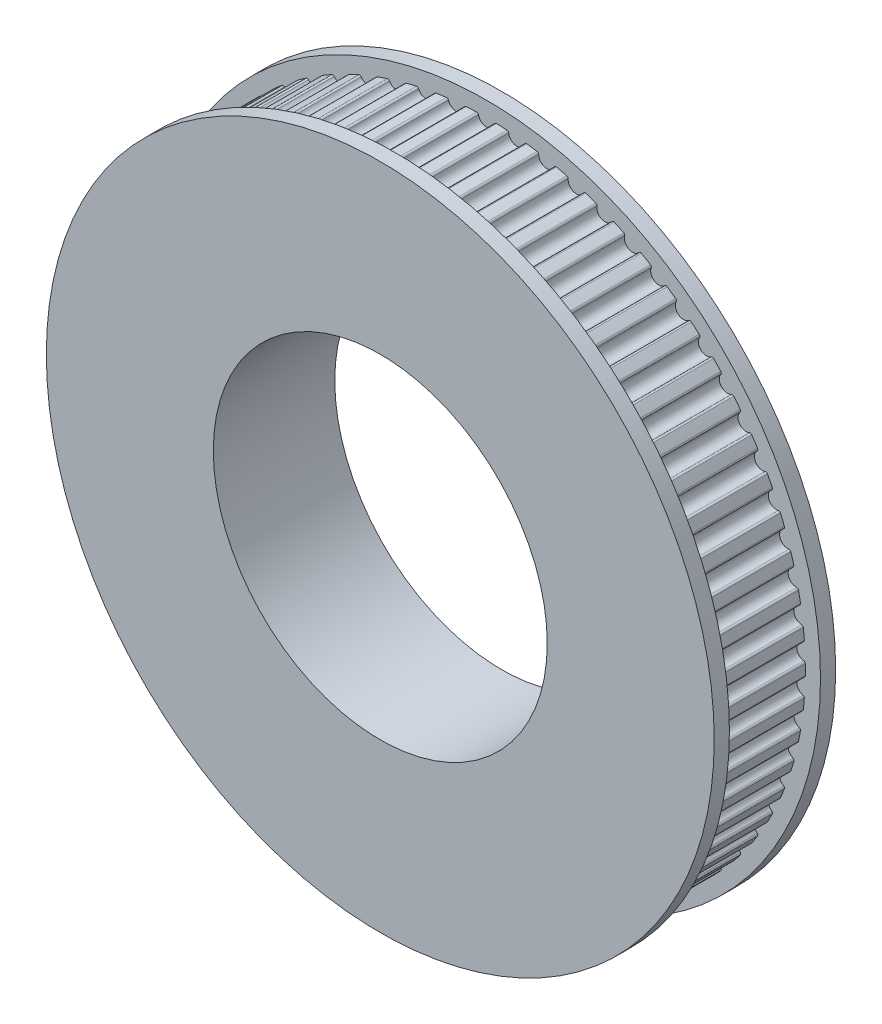
from build123d import *

# Parameters (mm, degrees)
SKETCH1_R           = 11
BOSS_EXTRUDE1_DEPTH = 6
SKETCH3_R           = 22
SKETCH3_R_2         = 11
BOSS_EXTRUDE2_DEPTH = 1
SKETCH4_R           = 22
SKETCH4_R_2         = 11
BOSS_EXTRUDE3_DEPTH = 1


with BuildPart() as part:
    # Sketch1 → Boss-Extrude1 (new body)
    with BuildSketch(Plane.XY):
        with BuildLine():
            ThreePointArc((-0.528729208, 20.890248339), (-0.573745596, 20.963017024), (-0.655019151, 20.989782039))
            ThreePointArc((-0.655019151, 20.989782039), (-0.999220235, 20.976214126), (-1.343152463, 20.95700221))
            ThreePointArc((-1.343152463, 20.95700221), (-1.421513828, 20.922632846), (-1.459409275, 20.845914583))
            ThreePointArc((-1.459409275, 20.845914583), (-1.944846649, 20.367355539), (-2.512079432, 20.74539677))
            ThreePointArc((-2.512079432, 20.74539677), (-2.563809085, 20.813556874), (-2.647258804, 20.832475153))
            ThreePointArc((-2.647258804, 20.832475153), (-2.988611607, 20.786250283), (-3.329160274, 20.734432523))
            ThreePointArc((-3.329160274, 20.734432523), (-3.403899797, 20.692770065), (-3.434331116, 20.612796997))
            ThreePointArc((-3.434331116, 20.612796997), (-3.872080463, 20.090261149), (-4.472679875, 20.412671677))
            ThreePointArc((-4.472679875, 20.412671677), (-4.530654323, 20.47560593), (-4.615524471, 20.486506145))
            ThreePointArc((-4.615524471, 20.486506145), (-4.950937649, 20.408042938), (-5.285018694, 20.324088604))
            ThreePointArc((-5.285018694, 20.324088604), (-5.355459522, 20.275510353), (-5.378151123, 20.193006729))
            ThreePointArc((-5.378151123, 20.193006729), (-5.764248116, 19.631226244), (-6.392775037, 19.895086267))
            ThreePointArc((-6.392775037, 19.895086267), (-6.456469253, 19.952224728), (-6.541991234, 19.955008165))
            ThreePointArc((-6.541991234, 19.955008165), (-6.868427233, 19.845017196), (-7.193015166, 19.729686592))
            ThreePointArc((-7.193015166, 19.729686592), (-7.258519377, 19.674632481), (-7.27326576, 19.590345465))
            ThreePointArc((-7.27326576, 19.590345465), (-7.604213846, 18.994407913), (-8.254976238, 19.197327876))
            ThreePointArc((-8.254976238, 19.197327876), (-8.323813397, 19.248153089), (-8.409212711, 19.242794542))
            ThreePointArc((-8.409212711, 19.242794542), (-8.723715276, 19.102271906), (-9.035870579, 18.956609482))
            ThreePointArc((-9.035870579, 18.956609482), (-9.095844956, 18.89557809), (-9.102512576, 18.810270999))
            ThreePointArc((-9.102512576, 18.810270999), (-9.375314638, 18.185573283), (-10.042419096, 18.32571551))
            ThreePointArc((-10.042419096, 18.32571551), (-10.115775799, 18.369767195), (-10.200279056, 18.356315191))
            ThreePointArc((-10.200279056, 18.356315191), (-10.500000003, 18.186533483), (-10.796895749, 18.011858382))
            ThreePointArc((-10.796895749, 18.011858382), (-10.850797155, 17.945402417), (-10.849325628, 17.859847807))
            ThreePointArc((-10.849325628, 17.859847807), (-11.061511128, 17.212047285), (-11.738916251, 17.288142628))
            ThreePointArc((-11.738916251, 17.288142628), (-11.816128169, 17.325021845), (-11.898970094, 17.303598207))
            ThreePointArc((-11.898970094, 17.303598207), (-12.181195104, 17.106094997), (-12.460142559, 16.903989103))
            ThreePointArc((-12.460142559, 16.903989103), (-12.507482854, 16.832710402), (-12.497885508, 16.747683066))
            ThreePointArc((-12.497885508, 16.747683066), (-12.647532861, 16.082646322), (-13.329103964, 16.094005648))
            ThreePointArc((-13.329103964, 16.094005648), (-13.409471852, 16.123378414), (-13.489902216, 16.094177158))
            ThreePointArc((-13.489902216, 16.094177158), (-13.752075416, 15.870741065), (-14.010548389, 15.643034681))
            ThreePointArc((-14.010548389, 15.643034681), (-14.050898852, 15.567578754), (-14.033262601, 15.483848715))
            ThreePointArc((-14.033262601, 15.483848715), (-14.119016578, 14.807598423), (-14.798581246, 14.754118861))
            ThreePointArc((-14.798581246, 14.754118861), (-14.881377281, 14.775719171), (-14.958667695, 14.739004749))
            ThreePointArc((-14.958667695, 14.739004749), (-15.198414803, 14.491659245), (-15.434072523, 14.240414515))
            ThreePointArc((-15.434072523, 14.240414515), (-15.467067734, 14.161464703), (-15.441552295, 14.079790232))
            ThreePointArc((-15.441552295, 14.079790232), (-15.462636294, 13.39845062), (-16.134040286, 13.280616489))
            ThreePointArc((-16.134040286, 13.280616489), (-16.218514654, 13.294248728), (-16.291965163, 13.250353631))
            ThreePointArc((-16.291965163, 13.250353631), (-16.507114993, 12.981338714), (-16.717823306, 12.70883095))
            ThreePointArc((-16.717823306, 12.70883095), (-16.743164455, 12.627102234), (-16.710000901, 12.548222988))
            ThreePointArc((-16.710000901, 12.548222988), (-16.666223982, 11.867964373), (-17.323386958, 11.686842798))
            ThreePointArc((-17.323386958, 11.686842798), (-17.408774646, 11.692383509), (-17.477720071, 11.641705258))
            ThreePointArc((-17.477720071, 11.641705258), (-17.666324193, 11.35345717), (-17.850174892, 11.062154244))
            ThreePointArc((-17.850174892, 11.062154244), (-17.867632487, 10.978386773), (-17.82712115, 10.903017094))
            ThreePointArc((-17.82712115, 10.903017094), (-17.718879765, 10.230000003), (-18.355850355, 9.987231248))
            ThreePointArc((-18.355850355, 9.987231248), (-18.44137808, 9.984630255), (-18.50519404, 9.927627799))
            ThreePointArc((-18.50519404, 9.927627799), (-18.665544425, 9.62275696), (-18.820872531, 9.315296955))
            ThreePointArc((-18.820872531, 9.315296955), (-18.830288471, 9.23024934), (-18.78279623, 9.159071789))
            ThreePointArc((-18.78279623, 9.159071789), (-18.611070628, 8.499391169), (-19.222080329, 8.197173786))
            ThreePointArc((-19.222080329, 8.197173786), (-19.306973537, 8.186454643), (-19.365082106, 8.123644206))
            ThreePointArc((-19.365082106, 8.123644206), (-19.495726597, 7.804911572), (-19.621125433, 7.484078896))
            ThreePointArc((-19.621125433, 7.484078896), (-19.622414448, 7.39852134), (-19.568371399, 7.332180511))
            ThreePointArc((-19.568371399, 7.332180511), (-19.334716754, 6.691810533), (-19.914232167, 6.332881448))
            ThreePointArc((-19.914232167, 6.332881448), (-19.997722053, 6.31414123), (-20.04959699, 6.246091633))
            ThreePointArc((-20.04959699, 6.246091633), (-20.149352449, 5.916383697), (-20.243686385, 5.585083858))
            ThreePointArc((-20.243686385, 5.585083858), (-20.236836801, 5.499791186), (-20.176732366, 5.438887871))
            ThreePointArc((-20.176732366, 5.438887871), (-19.883264691, 4.823627824), (-20.426037635, 4.411237556))
            ThreePointArc((-20.426037635, 4.411237556), (-20.507368101, 4.384645977), (-20.552539619, 4.311973487))
            ThreePointArc((-20.552539619, 4.311973487), (-20.620502646, 3.974276135), (-20.682917379, 3.635509437))
            ThreePointArc((-20.682917379, 3.635509437), (-20.667991226, 3.551254071), (-20.60236972, 3.496339821))
            ThreePointArc((-20.60236972, 3.496339821), (-20.251746704, 2.911761595), (-20.752861743, 2.449644813))
            ThreePointArc((-20.752861743, 2.449644813), (-20.831296248, 2.41544269), (-20.869355267, 2.338805442))
            ThreePointArc((-20.869355267, 2.338805442), (-20.904910377, 1.996176913), (-20.934840669, 1.653011279))
            ThreePointArc((-20.934840669, 1.653011279), (-20.911973121, 1.570556249), (-20.841428824, 1.522128375))
            ThreePointArc((-20.841428824, 1.522128375), (-20.436825763, 0.973526001), (-20.891744721, 0.465867707))
            ThreePointArc((-20.891744721, 0.465867707), (-20.96657295, 0.424364781), (-20.997174801, 0.344456812))
            ThreePointArc((-20.997174801, 0.344456812), (-21.000000003, 3e-09), (-20.997174801, -0.344456805))
            ThreePointArc((-20.997174801, -0.344456805), (-20.96657295, -0.424364774), (-20.891744721, -0.4658677))
            ThreePointArc((-20.891744721, -0.4658677), (-20.436825763, -0.973525994), (-20.841428824, -1.522128368))
            ThreePointArc((-20.841428824, -1.522128368), (-20.911973121, -1.570556242), (-20.934840669, -1.653011272))
            ThreePointArc((-20.934840669, -1.653011272), (-20.904910377, -1.996176906), (-20.869355267, -2.338805435))
            ThreePointArc((-20.869355267, -2.338805435), (-20.831296248, -2.415442683), (-20.752861743, -2.449644806))
            ThreePointArc((-20.752861743, -2.449644806), (-20.251746704, -2.911761588), (-20.60236972, -3.496339814))
            ThreePointArc((-20.60236972, -3.496339814), (-20.667991226, -3.551254064), (-20.682917379, -3.63550943))
            ThreePointArc((-20.682917379, -3.63550943), (-20.620502646, -3.974276128), (-20.552539619, -4.31197348))
            ThreePointArc((-20.552539619, -4.31197348), (-20.507368101, -4.38464597), (-20.426037635, -4.411237549))
            ThreePointArc((-20.426037635, -4.411237549), (-19.883264691, -4.823627817), (-20.176732366, -5.438887864))
            ThreePointArc((-20.176732366, -5.438887864), (-20.236836801, -5.499791179), (-20.243686385, -5.585083851))
            ThreePointArc((-20.243686385, -5.585083851), (-20.149352449, -5.91638369), (-20.04959699, -6.246091626))
            ThreePointArc((-20.04959699, -6.246091626), (-19.997722053, -6.314141223), (-19.914232167, -6.332881441))
            ThreePointArc((-19.914232167, -6.332881441), (-19.334716754, -6.691810526), (-19.568371399, -7.332180504))
            ThreePointArc((-19.568371399, -7.332180504), (-19.622414448, -7.398521334), (-19.621125433, -7.484078889))
            ThreePointArc((-19.621125433, -7.484078889), (-19.495726597, -7.804911565), (-19.365082106, -8.123644199))
            ThreePointArc((-19.365082106, -8.123644199), (-19.306973537, -8.186454636), (-19.222080329, -8.197173779))
            ThreePointArc((-19.222080329, -8.197173779), (-18.611070628, -8.499391163), (-18.78279623, -9.159071782))
            ThreePointArc((-18.78279623, -9.159071782), (-18.830288471, -9.230249333), (-18.820872531, -9.315296948))
            ThreePointArc((-18.820872531, -9.315296948), (-18.665544425, -9.622756953), (-18.50519404, -9.927627792))
            ThreePointArc((-18.50519404, -9.927627792), (-18.44137808, -9.984630248), (-18.355850355, -9.987231241))
            ThreePointArc((-18.355850355, -9.987231241), (-17.718879765, -10.229999997), (-17.82712115, -10.903017087))
            ThreePointArc((-17.82712115, -10.903017087), (-17.867632487, -10.978386766), (-17.850174892, -11.062154237))
            ThreePointArc((-17.850174892, -11.062154237), (-17.666324193, -11.353457163), (-17.477720071, -11.641705251))
            ThreePointArc((-17.477720071, -11.641705251), (-17.408774646, -11.692383502), (-17.323386958, -11.686842791))
            ThreePointArc((-17.323386958, -11.686842791), (-16.666223982, -11.867964366), (-16.710000901, -12.548222981))
            ThreePointArc((-16.710000901, -12.548222981), (-16.743164455, -12.627102227), (-16.717823306, -12.708830943))
            ThreePointArc((-16.717823306, -12.708830943), (-16.507114993, -12.981338707), (-16.291965163, -13.250353624))
            ThreePointArc((-16.291965163, -13.250353624), (-16.218514654, -13.294248721), (-16.134040286, -13.280616482))
            ThreePointArc((-16.134040286, -13.280616482), (-15.462636294, -13.398450613), (-15.441552295, -14.079790225))
            ThreePointArc((-15.441552295, -14.079790225), (-15.467067734, -14.161464696), (-15.434072523, -14.240414508))
            ThreePointArc((-15.434072523, -14.240414508), (-15.198414803, -14.491659238), (-14.958667695, -14.739004742))
            ThreePointArc((-14.958667695, -14.739004742), (-14.881377281, -14.775719164), (-14.798581246, -14.754118854))
            ThreePointArc((-14.798581246, -14.754118854), (-14.119016578, -14.807598416), (-14.033262601, -15.483848708))
            ThreePointArc((-14.033262601, -15.483848708), (-14.050898852, -15.567578747), (-14.010548389, -15.643034674))
            ThreePointArc((-14.010548389, -15.643034674), (-13.752075416, -15.870741058), (-13.489902216, -16.094177151))
            ThreePointArc((-13.489902216, -16.094177151), (-13.409471852, -16.123378407), (-13.329103964, -16.094005641))
            ThreePointArc((-13.329103964, -16.094005641), (-12.647532861, -16.082646315), (-12.497885508, -16.74768306))
            ThreePointArc((-12.497885508, -16.74768306), (-12.507482854, -16.832710395), (-12.460142559, -16.903989096))
            ThreePointArc((-12.460142559, -16.903989096), (-12.181195104, -17.10609499), (-11.898970094, -17.3035982))
            ThreePointArc((-11.898970094, -17.3035982), (-11.816128169, -17.325021838), (-11.738916251, -17.288142621))
            ThreePointArc((-11.738916251, -17.288142621), (-11.061511128, -17.212047278), (-10.849325628, -17.8598478))
            ThreePointArc((-10.849325628, -17.8598478), (-10.850797155, -17.94540241), (-10.796895749, -18.011858375))
            ThreePointArc((-10.796895749, -18.011858375), (-10.500000003, -18.186533476), (-10.200279056, -18.356315184))
            ThreePointArc((-10.200279056, -18.356315184), (-10.115775799, -18.369767188), (-10.042419096, -18.325715504))
            ThreePointArc((-10.042419096, -18.325715504), (-9.375314638, -18.185573276), (-9.102512576, -18.810270992))
            ThreePointArc((-9.102512576, -18.810270992), (-9.095844956, -18.895578083), (-9.035870579, -18.956609475))
            ThreePointArc((-9.035870579, -18.956609475), (-8.723715276, -19.102271899), (-8.409212711, -19.242794535))
            ThreePointArc((-8.409212711, -19.242794535), (-8.323813397, -19.248153082), (-8.254976238, -19.197327869))
            ThreePointArc((-8.254976238, -19.197327869), (-7.604213846, -18.994407906), (-7.27326576, -19.590345458))
            ThreePointArc((-7.27326576, -19.590345458), (-7.258519377, -19.674632474), (-7.193015166, -19.729686585))
            ThreePointArc((-7.193015166, -19.729686585), (-6.868427233, -19.84501719), (-6.541991234, -19.955008158))
            ThreePointArc((-6.541991234, -19.955008158), (-6.456469253, -19.952224721), (-6.392775037, -19.89508626))
            ThreePointArc((-6.392775037, -19.89508626), (-5.764248116, -19.631226237), (-5.378151123, -20.193006722))
            ThreePointArc((-5.378151123, -20.193006722), (-5.355459522, -20.275510347), (-5.285018694, -20.324088597))
            ThreePointArc((-5.285018694, -20.324088597), (-4.950937649, -20.408042931), (-4.615524471, -20.486506138))
            ThreePointArc((-4.615524471, -20.486506138), (-4.530654323, -20.475605923), (-4.472679875, -20.41267167))
            ThreePointArc((-4.472679875, -20.41267167), (-3.872080463, -20.090261143), (-3.434331116, -20.61279699))
            ThreePointArc((-3.434331116, -20.61279699), (-3.403899797, -20.692770058), (-3.329160274, -20.734432516))
            ThreePointArc((-3.329160274, -20.734432516), (-2.988611607, -20.786250276), (-2.647258804, -20.832475146))
            ThreePointArc((-2.647258804, -20.832475146), (-2.563809085, -20.813556867), (-2.512079432, -20.745396764))
            ThreePointArc((-2.512079432, -20.745396764), (-1.944846649, -20.367355532), (-1.459409275, -20.845914576))
            ThreePointArc((-1.459409275, -20.845914576), (-1.421513828, -20.922632839), (-1.343152463, -20.957002203))
            ThreePointArc((-1.343152463, -20.957002203), (-0.999220235, -20.976214119), (-0.655019151, -20.989782032))
            ThreePointArc((-0.655019151, -20.989782032), (-0.573745596, -20.963017017), (-0.528729208, -20.890248332))
            ThreePointArc((-0.528729208, -20.890248332), (-3e-09, -20.459999997), (0.528729202, -20.890248332))
            ThreePointArc((0.528729202, -20.890248332), (0.57374559, -20.963017017), (0.655019145, -20.989782032))
            ThreePointArc((0.655019145, -20.989782032), (0.999220229, -20.976214119), (1.343152456, -20.957002203))
            ThreePointArc((1.343152456, -20.957002203), (1.421513822, -20.922632839), (1.459409269, -20.845914576))
            ThreePointArc((1.459409269, -20.845914576), (1.944846643, -20.367355532), (2.512079425, -20.745396764))
            ThreePointArc((2.512079425, -20.745396764), (2.563809079, -20.813556867), (2.647258798, -20.832475146))
            ThreePointArc((2.647258798, -20.832475146), (2.988611601, -20.786250276), (3.329160267, -20.734432516))
            ThreePointArc((3.329160267, -20.734432516), (3.403899791, -20.692770058), (3.43433111, -20.61279699))
            ThreePointArc((3.43433111, -20.61279699), (3.872080456, -20.090261143), (4.472679869, -20.41267167))
            ThreePointArc((4.472679869, -20.41267167), (4.530654316, -20.475605923), (4.615524465, -20.486506138))
            ThreePointArc((4.615524465, -20.486506138), (4.950937643, -20.408042931), (5.285018687, -20.324088597))
            ThreePointArc((5.285018687, -20.324088597), (5.355459516, -20.275510347), (5.378151116, -20.193006722))
            ThreePointArc((5.378151116, -20.193006722), (5.76424811, -19.631226237), (6.39277503, -19.89508626))
            ThreePointArc((6.39277503, -19.89508626), (6.456469246, -19.952224721), (6.541991227, -19.955008158))
            ThreePointArc((6.541991227, -19.955008158), (6.868427226, -19.84501719), (7.19301516, -19.729686585))
            ThreePointArc((7.19301516, -19.729686585), (7.258519371, -19.674632474), (7.273265753, -19.590345458))
            ThreePointArc((7.273265753, -19.590345458), (7.60421384, -18.994407906), (8.254976231, -19.197327869))
            ThreePointArc((8.254976231, -19.197327869), (8.323813391, -19.248153082), (8.409212705, -19.242794535))
            ThreePointArc((8.409212705, -19.242794535), (8.72371527, -19.102271899), (9.035870573, -18.956609475))
            ThreePointArc((9.035870573, -18.956609475), (9.09584495, -18.895578083), (9.102512569, -18.810270992))
            ThreePointArc((9.102512569, -18.810270992), (9.375314631, -18.185573276), (10.042419089, -18.325715504))
            ThreePointArc((10.042419089, -18.325715504), (10.115775793, -18.369767188), (10.200279049, -18.356315184))
            ThreePointArc((10.200279049, -18.356315184), (10.499999997, -18.186533476), (10.796895743, -18.011858375))
            ThreePointArc((10.796895743, -18.011858375), (10.850797148, -17.94540241), (10.849325622, -17.8598478))
            ThreePointArc((10.849325622, -17.8598478), (11.061511122, -17.212047278), (11.738916245, -17.288142621))
            ThreePointArc((11.738916245, -17.288142621), (11.816128162, -17.325021838), (11.898970087, -17.3035982))
            ThreePointArc((11.898970087, -17.3035982), (12.181195098, -17.10609499), (12.460142553, -16.903989096))
            ThreePointArc((12.460142553, -16.903989096), (12.507482848, -16.832710395), (12.497885502, -16.74768306))
            ThreePointArc((12.497885502, -16.74768306), (12.647532855, -16.082646315), (13.329103957, -16.094005641))
            ThreePointArc((13.329103957, -16.094005641), (13.409471845, -16.123378407), (13.48990221, -16.094177151))
            ThreePointArc((13.48990221, -16.094177151), (13.75207541, -15.870741058), (14.010548382, -15.643034674))
            ThreePointArc((14.010548382, -15.643034674), (14.050898845, -15.567578747), (14.033262595, -15.483848708))
            ThreePointArc((14.033262595, -15.483848708), (14.119016572, -14.807598416), (14.79858124, -14.754118854))
            ThreePointArc((14.79858124, -14.754118854), (14.881377275, -14.775719164), (14.958667688, -14.739004742))
            ThreePointArc((14.958667688, -14.739004742), (15.198414797, -14.491659238), (15.434072516, -14.240414508))
            ThreePointArc((15.434072516, -14.240414508), (15.467067727, -14.161464696), (15.441552289, -14.079790225))
            ThreePointArc((15.441552289, -14.079790225), (15.462636288, -13.398450613), (16.134040279, -13.280616482))
            ThreePointArc((16.134040279, -13.280616482), (16.218514647, -13.294248721), (16.291965156, -13.250353624))
            ThreePointArc((16.291965156, -13.250353624), (16.507114986, -12.981338707), (16.717823299, -12.708830943))
            ThreePointArc((16.717823299, -12.708830943), (16.743164449, -12.627102227), (16.710000894, -12.548222981))
            ThreePointArc((16.710000894, -12.548222981), (16.666223976, -11.867964366), (17.323386952, -11.686842791))
            ThreePointArc((17.323386952, -11.686842791), (17.40877464, -11.692383502), (17.477720065, -11.641705251))
            ThreePointArc((17.477720065, -11.641705251), (17.666324186, -11.353457163), (17.850174886, -11.062154237))
            ThreePointArc((17.850174886, -11.062154237), (17.86763248, -10.978386766), (17.827121144, -10.903017087))
            ThreePointArc((17.827121144, -10.903017087), (17.718879758, -10.229999997), (18.355850349, -9.987231241))
            ThreePointArc((18.355850349, -9.987231241), (18.441378073, -9.984630248), (18.505194034, -9.927627792))
            ThreePointArc((18.505194034, -9.927627792), (18.665544419, -9.622756953), (18.820872524, -9.315296948))
            ThreePointArc((18.820872524, -9.315296948), (18.830288465, -9.230249333), (18.782796224, -9.159071782))
            ThreePointArc((18.782796224, -9.159071782), (18.611070622, -8.499391163), (19.222080323, -8.197173779))
            ThreePointArc((19.222080323, -8.197173779), (19.306973531, -8.186454636), (19.3650821, -8.123644199))
            ThreePointArc((19.3650821, -8.123644199), (19.49572659, -7.804911565), (19.621125427, -7.484078889))
            ThreePointArc((19.621125427, -7.484078889), (19.622414442, -7.398521334), (19.568371392, -7.332180504))
            ThreePointArc((19.568371392, -7.332180504), (19.334716748, -6.691810526), (19.914232161, -6.332881441))
            ThreePointArc((19.914232161, -6.332881441), (19.997722047, -6.314141223), (20.049596984, -6.246091626))
            ThreePointArc((20.049596984, -6.246091626), (20.149352443, -5.91638369), (20.243686379, -5.585083851))
            ThreePointArc((20.243686379, -5.585083851), (20.236836794, -5.499791179), (20.17673236, -5.438887864))
            ThreePointArc((20.17673236, -5.438887864), (19.883264685, -4.823627817), (20.426037629, -4.411237549))
            ThreePointArc((20.426037629, -4.411237549), (20.507368095, -4.38464597), (20.552539613, -4.31197348))
            ThreePointArc((20.552539613, -4.31197348), (20.620502639, -3.974276128), (20.682917372, -3.63550943))
            ThreePointArc((20.682917372, -3.63550943), (20.667991219, -3.551254064), (20.602369714, -3.496339814))
            ThreePointArc((20.602369714, -3.496339814), (20.251746698, -2.911761588), (20.752861736, -2.449644806))
            ThreePointArc((20.752861736, -2.449644806), (20.831296242, -2.415442683), (20.86935526, -2.338805435))
            ThreePointArc((20.86935526, -2.338805435), (20.904910371, -1.996176906), (20.934840663, -1.653011272))
            ThreePointArc((20.934840663, -1.653011272), (20.911973115, -1.570556242), (20.841428818, -1.522128368))
            ThreePointArc((20.841428818, -1.522128368), (20.436825757, -0.973525994), (20.891744715, -0.4658677))
            ThreePointArc((20.891744715, -0.4658677), (20.966572944, -0.424364774), (20.997174795, -0.344456805))
            ThreePointArc((20.997174795, -0.344456805), (20.999999997, 3e-09), (20.997174795, 0.344456812))
            ThreePointArc((20.997174795, 0.344456812), (20.966572944, 0.424364781), (20.891744715, 0.465867707))
            ThreePointArc((20.891744715, 0.465867707), (20.436825757, 0.973526001), (20.841428818, 1.522128375))
            ThreePointArc((20.841428818, 1.522128375), (20.911973115, 1.570556249), (20.934840663, 1.653011279))
            ThreePointArc((20.934840663, 1.653011279), (20.904910371, 1.996176913), (20.86935526, 2.338805442))
            ThreePointArc((20.86935526, 2.338805442), (20.831296242, 2.41544269), (20.752861736, 2.449644813))
            ThreePointArc((20.752861736, 2.449644813), (20.251746698, 2.911761595), (20.602369714, 3.496339821))
            ThreePointArc((20.602369714, 3.496339821), (20.667991219, 3.551254071), (20.682917372, 3.635509437))
            ThreePointArc((20.682917372, 3.635509437), (20.620502639, 3.974276135), (20.552539613, 4.311973487))
            ThreePointArc((20.552539613, 4.311973487), (20.507368095, 4.384645977), (20.426037629, 4.411237556))
            ThreePointArc((20.426037629, 4.411237556), (19.883264685, 4.823627824), (20.17673236, 5.438887871))
            ThreePointArc((20.17673236, 5.438887871), (20.236836794, 5.499791186), (20.243686379, 5.585083858))
            ThreePointArc((20.243686379, 5.585083858), (20.149352443, 5.916383697), (20.049596984, 6.246091633))
            ThreePointArc((20.049596984, 6.246091633), (19.997722047, 6.31414123), (19.914232161, 6.332881448))
            ThreePointArc((19.914232161, 6.332881448), (19.334716748, 6.691810533), (19.568371392, 7.332180511))
            ThreePointArc((19.568371392, 7.332180511), (19.622414442, 7.39852134), (19.621125427, 7.484078896))
            ThreePointArc((19.621125427, 7.484078896), (19.49572659, 7.804911572), (19.3650821, 8.123644206))
            ThreePointArc((19.3650821, 8.123644206), (19.306973531, 8.186454643), (19.222080323, 8.197173786))
            ThreePointArc((19.222080323, 8.197173786), (18.611070622, 8.499391169), (18.782796224, 9.159071789))
            ThreePointArc((18.782796224, 9.159071789), (18.830288465, 9.23024934), (18.820872524, 9.315296955))
            ThreePointArc((18.820872524, 9.315296955), (18.665544419, 9.62275696), (18.505194034, 9.927627799))
            ThreePointArc((18.505194034, 9.927627799), (18.441378073, 9.984630255), (18.355850349, 9.987231248))
            ThreePointArc((18.355850349, 9.987231248), (17.718879758, 10.230000003), (17.827121144, 10.903017094))
            ThreePointArc((17.827121144, 10.903017094), (17.86763248, 10.978386773), (17.850174886, 11.062154244))
            ThreePointArc((17.850174886, 11.062154244), (17.666324186, 11.35345717), (17.477720065, 11.641705258))
            ThreePointArc((17.477720065, 11.641705258), (17.40877464, 11.692383509), (17.323386952, 11.686842798))
            ThreePointArc((17.323386952, 11.686842798), (16.666223976, 11.867964373), (16.710000894, 12.548222988))
            ThreePointArc((16.710000894, 12.548222988), (16.743164449, 12.627102234), (16.717823299, 12.70883095))
            ThreePointArc((16.717823299, 12.70883095), (16.507114986, 12.981338714), (16.291965156, 13.250353631))
            ThreePointArc((16.291965156, 13.250353631), (16.218514647, 13.294248728), (16.134040279, 13.280616489))
            ThreePointArc((16.134040279, 13.280616489), (15.462636288, 13.39845062), (15.441552289, 14.079790232))
            ThreePointArc((15.441552289, 14.079790232), (15.467067727, 14.161464703), (15.434072516, 14.240414515))
            ThreePointArc((15.434072516, 14.240414515), (15.198414797, 14.491659245), (14.958667688, 14.739004749))
            ThreePointArc((14.958667688, 14.739004749), (14.881377275, 14.775719171), (14.79858124, 14.754118861))
            ThreePointArc((14.79858124, 14.754118861), (14.119016572, 14.807598423), (14.033262595, 15.483848715))
            ThreePointArc((14.033262595, 15.483848715), (14.050898845, 15.567578754), (14.010548382, 15.643034681))
            ThreePointArc((14.010548382, 15.643034681), (13.75207541, 15.870741065), (13.48990221, 16.094177158))
            ThreePointArc((13.48990221, 16.094177158), (13.409471845, 16.123378414), (13.329103957, 16.094005648))
            ThreePointArc((13.329103957, 16.094005648), (12.647532855, 16.082646322), (12.497885502, 16.747683066))
            ThreePointArc((12.497885502, 16.747683066), (12.507482848, 16.832710402), (12.460142553, 16.903989103))
            ThreePointArc((12.460142553, 16.903989103), (12.181195098, 17.106094997), (11.898970087, 17.303598207))
            ThreePointArc((11.898970087, 17.303598207), (11.816128162, 17.325021845), (11.738916245, 17.288142628))
            ThreePointArc((11.738916245, 17.288142628), (11.061511122, 17.212047285), (10.849325622, 17.859847807))
            ThreePointArc((10.849325622, 17.859847807), (10.850797148, 17.945402417), (10.796895743, 18.011858382))
            ThreePointArc((10.796895743, 18.011858382), (10.499999997, 18.186533483), (10.200279049, 18.356315191))
            ThreePointArc((10.200279049, 18.356315191), (10.115775793, 18.369767195), (10.042419089, 18.32571551))
            ThreePointArc((10.042419089, 18.32571551), (9.375314631, 18.185573283), (9.102512569, 18.810270999))
            ThreePointArc((9.102512569, 18.810270999), (9.09584495, 18.89557809), (9.035870573, 18.956609482))
            ThreePointArc((9.035870573, 18.956609482), (8.72371527, 19.102271906), (8.409212705, 19.242794542))
            ThreePointArc((8.409212705, 19.242794542), (8.323813391, 19.248153089), (8.254976231, 19.197327876))
            ThreePointArc((8.254976231, 19.197327876), (7.60421384, 18.994407913), (7.273265753, 19.590345465))
            ThreePointArc((7.273265753, 19.590345465), (7.258519371, 19.674632481), (7.19301516, 19.729686592))
            ThreePointArc((7.19301516, 19.729686592), (6.868427226, 19.845017196), (6.541991227, 19.955008165))
            ThreePointArc((6.541991227, 19.955008165), (6.456469246, 19.952224728), (6.39277503, 19.895086267))
            ThreePointArc((6.39277503, 19.895086267), (5.76424811, 19.631226244), (5.378151116, 20.193006729))
            ThreePointArc((5.378151116, 20.193006729), (5.355459516, 20.275510353), (5.285018687, 20.324088604))
            ThreePointArc((5.285018687, 20.324088604), (4.950937643, 20.408042938), (4.615524465, 20.486506145))
            ThreePointArc((4.615524465, 20.486506145), (4.530654316, 20.47560593), (4.472679869, 20.412671677))
            ThreePointArc((4.472679869, 20.412671677), (3.872080456, 20.090261149), (3.43433111, 20.612796997))
            ThreePointArc((3.43433111, 20.612796997), (3.403899791, 20.692770065), (3.329160267, 20.734432523))
            ThreePointArc((3.329160267, 20.734432523), (2.988611601, 20.786250283), (2.647258798, 20.832475153))
            ThreePointArc((2.647258798, 20.832475153), (2.563809079, 20.813556874), (2.512079425, 20.74539677))
            ThreePointArc((2.512079425, 20.74539677), (1.944846643, 20.367355539), (1.459409269, 20.845914583))
            ThreePointArc((1.459409269, 20.845914583), (1.421513822, 20.922632846), (1.343152456, 20.95700221))
            ThreePointArc((1.343152456, 20.95700221), (0.999220229, 20.976214126), (0.655019145, 20.989782039))
            ThreePointArc((0.655019145, 20.989782039), (0.57374559, 20.963017024), (0.528729202, 20.890248339))
            ThreePointArc((0.528729202, 20.890248339), (-3e-09, 20.460000003), (-0.528729208, 20.890248339))
        make_face()
        with Locations((-3e-09, 3e-09)):
            Circle(SKETCH1_R, mode=Mode.SUBTRACT)
    extrude(amount=BOSS_EXTRUDE1_DEPTH)

    # Sketch3 → Boss-Extrude2 (add)
    with BuildSketch(Plane.XY.offset(6)):
        Circle(SKETCH3_R)
        Circle(SKETCH3_R_2, mode=Mode.SUBTRACT)
    extrude(amount=BOSS_EXTRUDE2_DEPTH)

    # Sketch4 → Boss-Extrude3 (add)
    with BuildSketch(Plane(origin=(0, 0, 0), x_dir=(-1, 0, 0), z_dir=(0, 0, -1))):
        with Locations((3e-09, 3e-09)):
            Circle(SKETCH4_R)
        with Locations((3e-09, 3e-09)):
            Circle(SKETCH4_R_2, mode=Mode.SUBTRACT)
    extrude(amount=BOSS_EXTRUDE3_DEPTH)


solid = part.part
